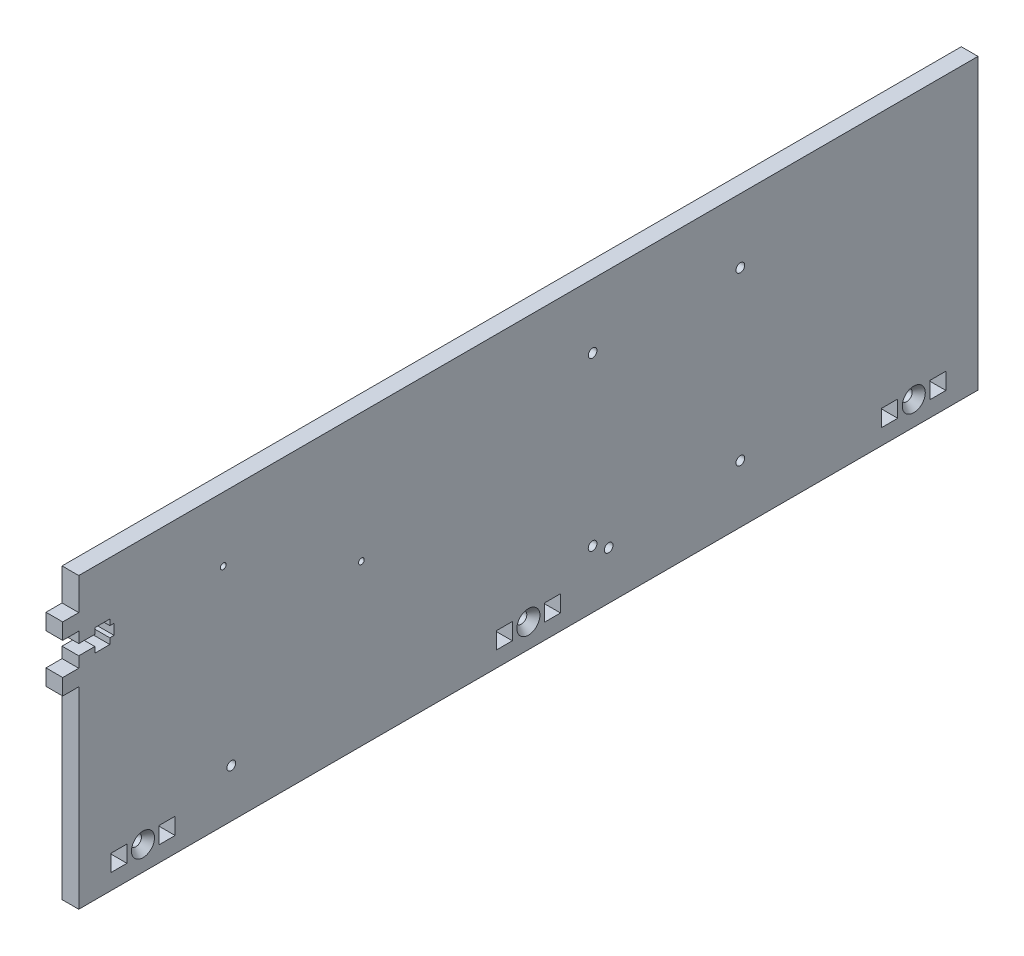
from build123d import *

# Parameters (mm, degrees)
SKETCH1_W                                         = 355.6
SKETCH1_H                                         = 114.3
SKETCH1_R                                         = 2.15265
SKETCH1_W_2                                       = 6.35
SKETCH1_H_2                                       = 6.604
BOSS_EXTRUDE1_DEPTH                               = 6.604
CUT_EXTRUDE1_DEPTH                                = 7.604
SKETCH6_W                                         = 6.35
SKETCH6_H                                         = 6.35
BOSS_EXTRUDE2_DEPTH                               = 6.604
CSK_FOR_8_FLAT_HEAD_SOCKET_CAP_SCREW2_D           = 4.3053
CSK_FOR_8_FLAT_HEAD_SOCKET_CAP_SCREW2_CSINK_D     = 9.1186
CSK_FOR_8_FLAT_HEAD_SOCKET_CAP_SCREW2_CSINK_ANGLE = 82
F_4_40_TAPPED_HOLE2_D                             = 2.2606
F_4_40_TAPPED_HOLE2_DEPTH                         = 7.5946
F_4_40_TAPPED_HOLE2_TIP                           = 0.679152758
F_8_32_TAPPED_HOLE1_D                             = 3.4544
F_8_32_TAPPED_HOLE1_DEPTH                         = 10.7188
F_8_32_TAPPED_HOLE1_TIP                           = 1.037806461
F_8_32_TAPPED_HOLE2_D                             = 3.4544
F_8_32_TAPPED_HOLE2_DEPTH                         = 10.7188
F_8_32_TAPPED_HOLE2_TIP                           = 1.037806461


with BuildPart() as part:
    # Sketch1 → Boss-Extrude1 (new body)
    with BuildSketch(Plane(origin=(0, 0, 0), x_dir=(0, 0, -1), z_dir=(1, 0, 0))):
        with Locations((0, 57.15)):
            Rectangle(SKETCH1_W, SKETCH1_H)
        with Locations((-152.4, 9.525)):
            Circle(SKETCH1_R, mode=Mode.SUBTRACT)
        with Locations((0, 9.525)):
            Circle(SKETCH1_R, mode=Mode.SUBTRACT)
        with Locations((152.4, 9.525)):
            Circle(SKETCH1_R, mode=Mode.SUBTRACT)
        with Locations((-142.875, 9.525)):
            Rectangle(SKETCH1_W_2, SKETCH1_H_2, mode=Mode.SUBTRACT)
        with Locations((-161.925, 9.525)):
            Rectangle(SKETCH1_W_2, SKETCH1_H_2, mode=Mode.SUBTRACT)
        with Locations((9.525, 9.525)):
            Rectangle(SKETCH1_W_2, SKETCH1_H_2, mode=Mode.SUBTRACT)
        with Locations((-9.525, 9.525)):
            Rectangle(SKETCH1_W_2, SKETCH1_H_2, mode=Mode.SUBTRACT)
        with Locations((161.925, 9.525)):
            Rectangle(SKETCH1_W_2, SKETCH1_H_2, mode=Mode.SUBTRACT)
        with Locations((142.875, 9.525)):
            Rectangle(SKETCH1_W_2, SKETCH1_H_2, mode=Mode.SUBTRACT)
    extrude(amount=BOSS_EXTRUDE1_DEPTH)

    # Sketch5 → Cut-Extrude1 (cut, through all)
    with BuildSketch(Plane.ZY):
        Polygon((177.8, 90.9828), (171.45, 90.9828), (171.45, 93.2688), (165.5064, 93.2688), (165.5064, 90.9828), (163.83, 90.9828), (163.83, 86.8172), (165.5064, 86.8172), (165.5064, 84.5312), (171.45, 84.5312), (171.45, 86.8172), (177.8, 86.8172), align=None)
    extrude(amount=-CUT_EXTRUDE1_DEPTH, mode=Mode.SUBTRACT)

    # Sketch6 → Boss-Extrude2 (add)
    with BuildSketch(Plane.ZY):
        with Locations((180.975, 98.425)):
            Rectangle(SKETCH6_W, SKETCH6_H)
        with Locations((180.975, 79.375)):
            Rectangle(SKETCH6_W, SKETCH6_H)
    extrude(amount=-BOSS_EXTRUDE2_DEPTH)

    # CSK for #8 Flat Head Socket Cap Screw2 (through all)
    with Locations(Plane(origin=(6.604, 0, 0), x_dir=(0, 0, -1), z_dir=(1, 0, 0))):
        with Locations((-152.4, 9.525), (0, 9.525), (152.4, 9.525)):
            CounterSinkHole(CSK_FOR_8_FLAT_HEAD_SOCKET_CAP_SCREW2_D / 2, CSK_FOR_8_FLAT_HEAD_SOCKET_CAP_SCREW2_CSINK_D / 2, counter_sink_angle=CSK_FOR_8_FLAT_HEAD_SOCKET_CAP_SCREW2_CSINK_ANGLE)

    # #4-40 Tapped Hole2
    with Locations(Plane.ZY):
        with Locations((120.65, 88.9), (66.04, 63.2968)):
            Hole(F_4_40_TAPPED_HOLE2_D / 2, depth=F_4_40_TAPPED_HOLE2_DEPTH)
            with Locations((0, 0, -(F_4_40_TAPPED_HOLE2_DEPTH + F_4_40_TAPPED_HOLE2_TIP / 2))):  # 118° drill point
                Cone(0, F_4_40_TAPPED_HOLE2_D / 2, F_4_40_TAPPED_HOLE2_TIP, mode=Mode.SUBTRACT)

    # #8-32 Tapped Hole1
    with Locations(Plane.ZY):
        with Locations((-83.82, 88.9), (-25.4, 88.9), (-83.82, 22.86), (-25.4, 22.86)):
            Hole(F_8_32_TAPPED_HOLE1_D / 2, depth=F_8_32_TAPPED_HOLE1_DEPTH)
            with Locations((0, 0, -(F_8_32_TAPPED_HOLE1_DEPTH + F_8_32_TAPPED_HOLE1_TIP / 2))):  # 118° drill point
                Cone(0, F_8_32_TAPPED_HOLE1_D / 2, F_8_32_TAPPED_HOLE1_TIP, mode=Mode.SUBTRACT)

    # #8-32 Tapped Hole2
    with Locations(Plane(origin=(6.604, 0, 0), x_dir=(0, 0, -1), z_dir=(1, 0, 0))):
        with Locations((-117.475, 19.05), (31.75, 19.05)):
            Hole(F_8_32_TAPPED_HOLE2_D / 2, depth=F_8_32_TAPPED_HOLE2_DEPTH)
            with Locations((0, 0, -(F_8_32_TAPPED_HOLE2_DEPTH + F_8_32_TAPPED_HOLE2_TIP / 2))):  # 118° drill point
                Cone(0, F_8_32_TAPPED_HOLE2_D / 2, F_8_32_TAPPED_HOLE2_TIP, mode=Mode.SUBTRACT)


solid = part.part
